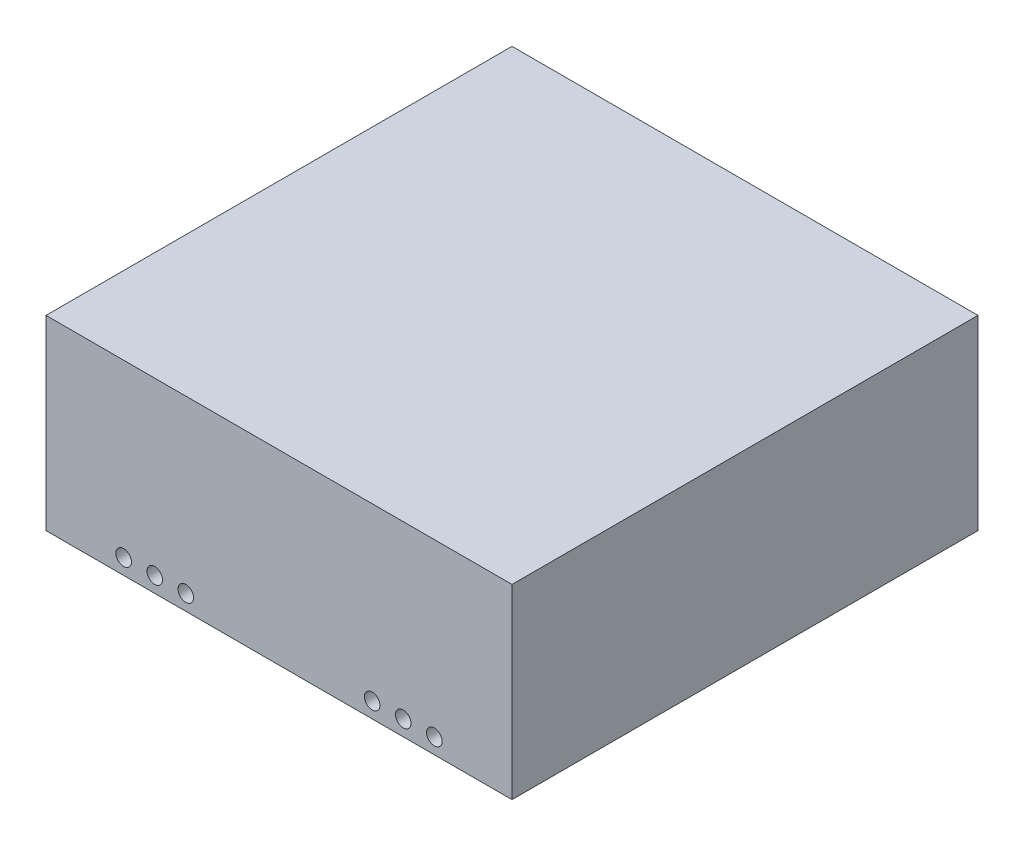
from build123d import *

# Parameters (mm, degrees)
SKETCH1_W           = 150
SKETCH1_H           = 150
BOSS_EXTRUDE1_DEPTH = 60
SHELL1_T            = -7.5
SKETCH5_R           = 2.5
CUT_EXTRUDE2_DEPTH  = 10
SKETCH6_R           = 1.5
CUT_EXTRUDE3_DEPTH  = 10


with BuildPart() as part:
    # Sketch1 → Boss-Extrude1 (new body)
    with BuildSketch(Plane(origin=(0, 0, 0), x_dir=(1, 0, 0), z_dir=(0, 1, 0))):
        Rectangle(SKETCH1_W, SKETCH1_H)
    extrude(amount=BOSS_EXTRUDE1_DEPTH)

    # Shell1
    shell1_openings = [part.faces().sort_by_distance(p)[0] for p in [
        (0, 0, 0),
    ]]
    offset(amount=SHELL1_T, openings=shell1_openings, kind=Kind.INTERSECTION)

    # Sketch5 → Cut-Extrude2 (cut)
    with BuildSketch(Plane.XY.offset(75)):
        with Locations((-50, 5)):
            Circle(SKETCH5_R)
        with Locations((-40, 5)):
            Circle(SKETCH5_R)
        with Locations((-30, 5)):
            Circle(SKETCH5_R)
        with Locations((30, 5)):
            Circle(SKETCH5_R)
        with Locations((40, 5)):
            Circle(SKETCH5_R)
        with Locations((50, 5)):
            Circle(SKETCH5_R)
    extrude(amount=-CUT_EXTRUDE2_DEPTH, mode=Mode.SUBTRACT)

    # Sketch6 → Cut-Extrude3 (cut)
    with BuildSketch(Plane(origin=(0, 0, -75), x_dir=(-1, 0, 0), z_dir=(0, 0, -1))):
        with Locations((-14.5, 8)):
            Circle(SKETCH6_R)
        with Locations((14.5, 8)):
            Circle(SKETCH6_R)
    extrude(amount=-CUT_EXTRUDE3_DEPTH, mode=Mode.SUBTRACT)


solid = part.part
